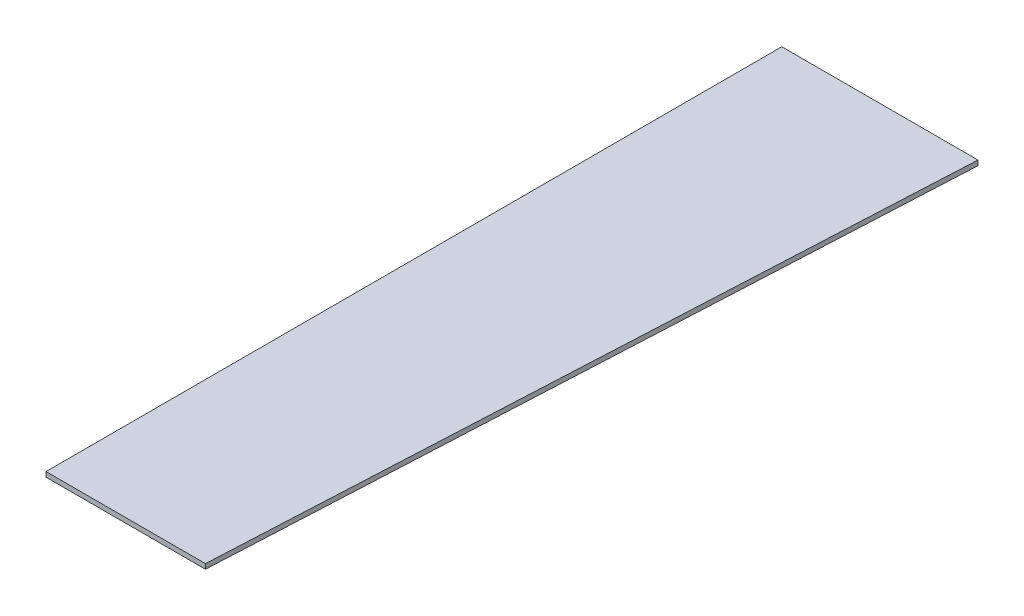
from build123d import *

# Parameters (mm, degrees)
EXTRUSION1_DEPTH = 10


with BuildPart() as part:
    # Esquisse1 → Extrusion1 (new body)
    with BuildSketch(Plane(origin=(0, 0, 0), x_dir=(1, 0, 0), z_dir=(0, 1, 0))):
        Polygon((0, 0), (400, 0), (325, -1500), (0, -1500), align=None)
    extrude(amount=EXTRUSION1_DEPTH)


solid = part.part
